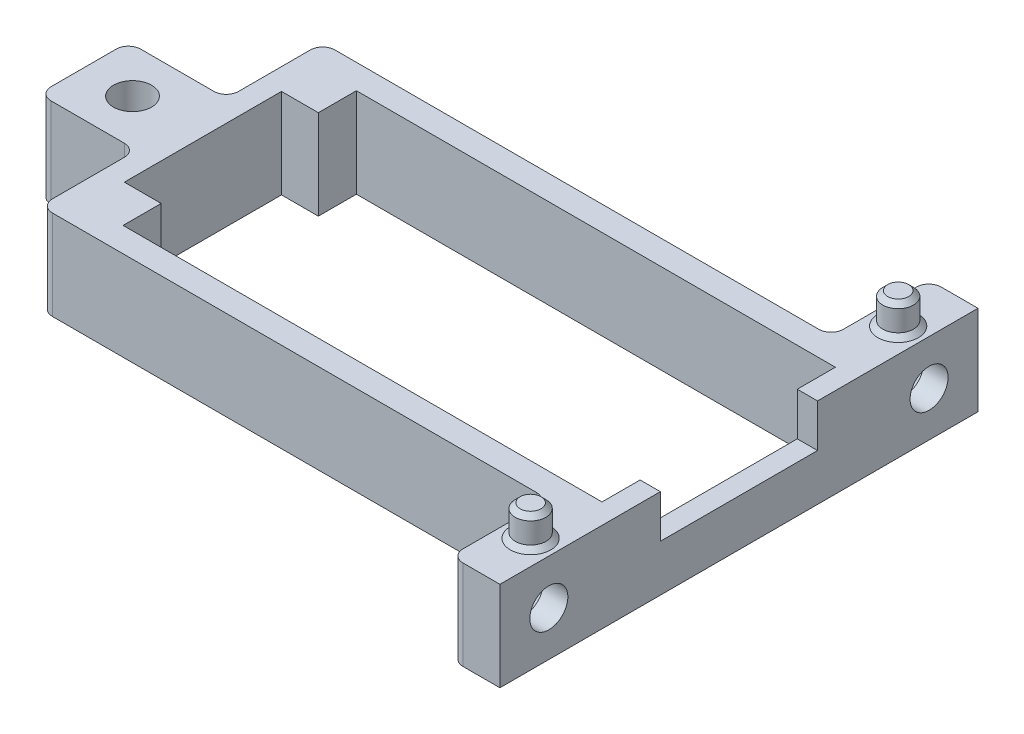
from build123d import *

# Parameters (mm, degrees)
CROQUIS1_R              = 1.55
SALIENTE_EXTRUIR1_DEPTH = 7.3
CROQUIS5_W              = 12.8
CROQUIS5_H              = 3.5
CORTAR_EXTRUIR4_DEPTH   = 1.65
CORTAR_EXTRUIR5_DEPTH   = 5
CROQUIS6_W              = 7.965212315
CROQUIS6_H              = 7.3
CROQUIS6_R              = 1.55
SALIENTE_EXTRUIR2_DEPTH = 4
CORTAR_EXTRUIR6_DEPTH   = 2
REDONDEO1_R             = 1
CROQUIS8_R              = 1.25
SALIENTE_EXTRUIR3_DEPTH = 2.5
CHAFL_N1_SIZE           = 0.4


with BuildPart() as part:
    # Croquis1 → Saliente-Extruir1 (new body)
    with BuildSketch(Plane(origin=(0, 0, 0), x_dir=(1, 0, 0), z_dir=(0, 1, 0))):
        Polygon((-24.25, 11.5), (-24.25, 3.65), (-32.215212315, 3.65), (-32.215212315, -3.65), (-24.25, -3.65), (-24.25, -11.5), (21.15, -11.5), (21.15, 11.5), align=None)
        with Locations((-28.232606158, 0)):
            Circle(CROQUIS1_R, mode=Mode.SUBTRACT)
        Polygon((-19.5, 9.5), (19.5, 9.5), (19.5, 6.4), (19.5, -6.4), (19.5, -9.5), (-19.5, -9.5), (-19.5, -6.4), (-22.5, -6.4), (-22.5, 6.4), (-19.5, 6.4), align=None, mode=Mode.SUBTRACT)
    extrude(amount=SALIENTE_EXTRUIR1_DEPTH)

    # Croquis5 → Cortar-Extruir4 (cut)
    with BuildSketch(Plane(origin=(21.15, 0, 0), x_dir=(0, 0, -1), z_dir=(1, 0, 0))):
        with Locations((0, 5.55)):
            Rectangle(CROQUIS5_W, CROQUIS5_H)
    extrude(amount=-CORTAR_EXTRUIR4_DEPTH, mode=Mode.SUBTRACT)

    # Croquis4 → Cortar-Extruir5 (cut)
    with BuildSketch(Plane.XZ):
        Polygon((-26.991303079, 2.15), (-25.75, 0), (-26.991303079, -2.15), (-29.473909236, -2.15), (-30.715212315, 0), (-29.473909236, 2.15), align=None)
    extrude(amount=-CORTAR_EXTRUIR5_DEPTH, mode=Mode.SUBTRACT)

    # Croquis6 → Saliente-Extruir2 (add)
    with BuildSketch(Plane(origin=(21.15, 0, 0), x_dir=(0, 0, -1), z_dir=(1, 0, 0))):
        with Locations((15.482606158, 3.65)):
            Rectangle(CROQUIS6_W, CROQUIS6_H)
        with Locations((15.482606158, 3.65)):
            Circle(CROQUIS6_R, mode=Mode.SUBTRACT)
        with Locations((-15.482606158, 3.65)):
            Rectangle(CROQUIS6_W, CROQUIS6_H)
        with Locations((-15.482606158, 3.65)):
            Circle(CROQUIS6_R, mode=Mode.SUBTRACT)
    extrude(amount=-SALIENTE_EXTRUIR2_DEPTH)

    # Croquis7 → Cortar-Extruir6 (cut)
    with BuildSketch(Plane.ZY.offset(-17.15)):
        Polygon((-17.965212315, 3.65), (-16.723909236, 5.8), (-14.241303079, 5.8), (-13, 3.65), (-14.241303079, 1.5), (-16.723909236, 1.5), align=None)
        Polygon((16.723909236, 1.5), (17.965212315, 3.65), (16.723909236, 5.8), (14.241303079, 5.8), (13, 3.65), (14.241303079, 1.5), align=None)
    extrude(amount=-CORTAR_EXTRUIR6_DEPTH, mode=Mode.SUBTRACT)

    # Redondeo1
    redondeo1_edges = [part.edges().sort_by_distance(p)[0] for p in [
        (17.15, 3.65, 11.5),
        (17.15, 3.65, 19.465212315),
        (-24.25, 3.65, 11.5),
        (-24.25, 3.65, 3.65),
        (-32.215212315, 3.65, 3.65),
        (-32.215212315, 3.65, -3.65),
        (-24.25, 3.65, -3.65),
        (-24.25, 3.65, -11.5),
        (17.15, 3.65, -19.465212315),
        (17.15, 3.65, -11.5),
    ]]
    fillet(redondeo1_edges, radius=REDONDEO1_R)

    # Croquis8 → Saliente-Extruir3 (add)
    with BuildSketch(Plane(origin=(0, 7.3, 0), x_dir=(1, 0, 0), z_dir=(0, 1, 0))):
        with Locations((19.15, -14.965212315)):
            Circle(CROQUIS8_R)
        with Locations((19.15, 14.965212315)):
            Circle(CROQUIS8_R)
    extrude(amount=SALIENTE_EXTRUIR3_DEPTH)

    # Chaflán1
    chafl_n1_edges = [part.edges().sort_by_distance(p)[0] for p in [
        (17.9, 7.3, 14.965212315),
        (17.9, 9.8, 14.965212315),
        (17.9, 7.3, -14.965212315),
        (17.9, 9.8, -14.965212315),
    ]]
    chamfer(chafl_n1_edges, length=CHAFL_N1_SIZE)


solid = part.part
